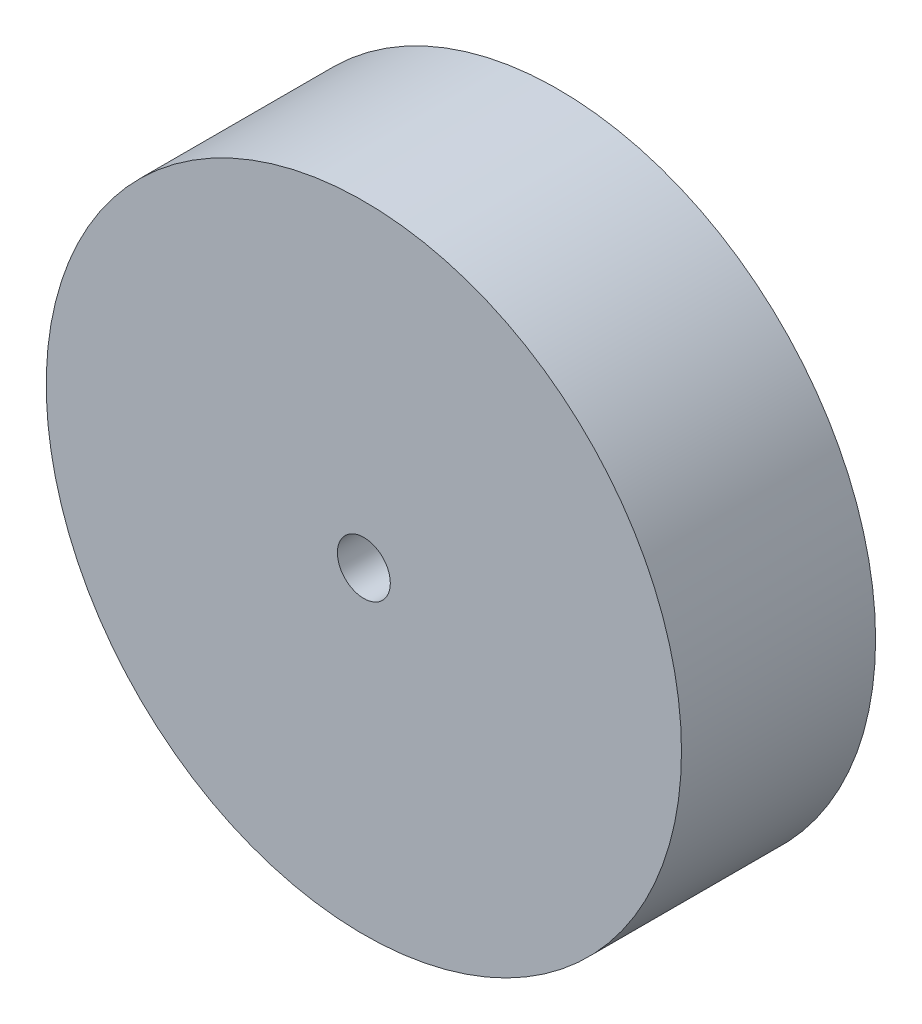
from build123d import *

# Parameters (mm, degrees)
SKETCH_1_R          = 2.75
EXTRUDE_1_DEPTH     = 3
SKETCH_2_R          = 9
EXTRUDE_2_DEPTH     = 5.5
SKETCH_3_R          = 0.75
CUT_EXTRUDE_1_DEPTH = 7.5
CHAMFER_1_SIZE      = 0.7


with BuildPart() as part:
    # Эскиз1 → Бобышка-Вытянуть1 (new body)
    with BuildSketch(Plane.XY):
        Circle(SKETCH_1_R)
    extrude(amount=EXTRUDE_1_DEPTH)

    # Эскиз2 → Бобышка-Вытянуть2 (add)
    with BuildSketch(Plane.XY.offset(3)):
        Circle(SKETCH_2_R)
    extrude(amount=EXTRUDE_2_DEPTH)

    # Эскиз3 → Вырез-Вытянуть1 (cut)
    with BuildSketch(Plane.XY.offset(8.5)):
        Circle(SKETCH_3_R)
    extrude(amount=-CUT_EXTRUDE_1_DEPTH, mode=Mode.SUBTRACT)

    # Фаска1
    chamfer_1_edges = [part.edges().sort_by_distance(p)[0] for p in [
        (-0.75, 0, 1),
    ]]
    chamfer(chamfer_1_edges, length=CHAMFER_1_SIZE)


solid = part.part
